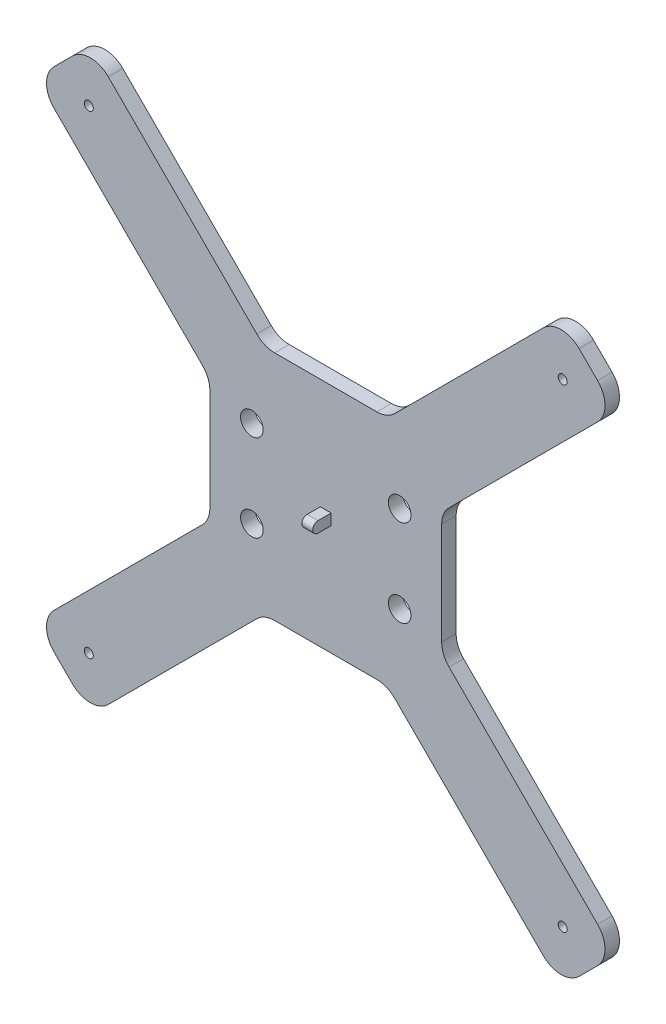
from build123d import *

# Parameters (mm, degrees)
BOSS_EXTRUDE1_DEPTH = 5.08
FILLET1_R           = 8.89
SKETCH2_R           = 3.96875
CUT_EXTRUDE1_DEPTH  = 6.08
SKETCH3_R           = 1.5875
CUT_EXTRUDE2_DEPTH  = 6.08
BOSS_EXTRUDE3_DEPTH = 1.905


with BuildPart() as part:
    # Sketch1 → Boss-Extrude1 (new body)
    with BuildSketch(Plane.XY):
        Polygon((0, 184.15), (60.96, 123.19), (60.96, 80.01), (0, 19.05), (19.05, 0), (80.01, 60.96), (123.19, 60.96), (184.15, 0), (203.2, 19.05), (142.24, 80.01), (142.24, 123.19), (203.2, 184.15), (184.15, 203.2), (123.19, 142.24), (80.01, 142.24), (19.05, 203.2), align=None)
    extrude(amount=BOSS_EXTRUDE1_DEPTH)

    # Fillet1
    fillet1_edges = [part.edges().sort_by_distance(p)[0] for p in [
        (19.05, 203.2, 2.54),
        (80.01, 142.24, 2.54),
        (123.19, 142.24, 2.54),
        (184.15, 203.2, 2.54),
        (203.2, 184.15, 2.54),
        (142.24, 123.19, 2.54),
        (142.24, 80.01, 2.54),
        (203.2, 19.05, 2.54),
        (184.15, 0, 2.54),
        (123.19, 60.96, 2.54),
        (80.01, 60.96, 2.54),
        (19.05, 0, 2.54),
        (0, 19.05, 2.54),
        (60.96, 80.01, 2.54),
        (60.96, 123.19, 2.54),
        (0, 184.15, 2.54),
    ]]
    fillet(fillet1_edges, radius=FILLET1_R)

    # Sketch2 → Cut-Extrude1 (cut, through all)
    with BuildSketch(Plane.XY.offset(5.08)):
        with Locations((127.508, 86.36)):
            Circle(SKETCH2_R)
        with Locations((127.508, 116.84)):
            Circle(SKETCH2_R)
        with Locations((75.692, 86.36)):
            Circle(SKETCH2_R)
        with Locations((75.692, 116.84)):
            Circle(SKETCH2_R)
    extrude(amount=-CUT_EXTRUDE1_DEPTH, mode=Mode.SUBTRACT)

    # Sketch3 → Cut-Extrude2 (cut, through all)
    with BuildSketch(Plane.XY.offset(5.08)):
        with Locations((184.688815367, 184.700672391)):
            Circle(SKETCH3_R)
        with Locations((18.511184633, 184.700672391)):
            Circle(SKETCH3_R)
        with Locations((18.511184633, 18.499327609)):
            Circle(SKETCH3_R)
        with Locations((184.688815367, 18.499327609)):
            Circle(SKETCH3_R)
    extrude(amount=-CUT_EXTRUDE2_DEPTH, mode=Mode.SUBTRACT)

    # Sketch5 → Boss-Extrude3 (add, symmetric)
    with BuildSketch(Plane(origin=(101.6, 0, 0), x_dir=(0, 0, -1), z_dir=(1, 0, 0))):
        with BuildLine():
            Line((-5.08, 99.695), (-5.08, 103.505))
            Line((-5.08, 103.505), (-9.652, 103.505))
            ThreePointArc((-9.652, 103.505), (-11.557, 101.6), (-9.652, 99.695))
            Line((-9.652, 99.695), (-5.08, 99.695))
        make_face()
    extrude(amount=BOSS_EXTRUDE3_DEPTH, both=True)


solid = part.part
